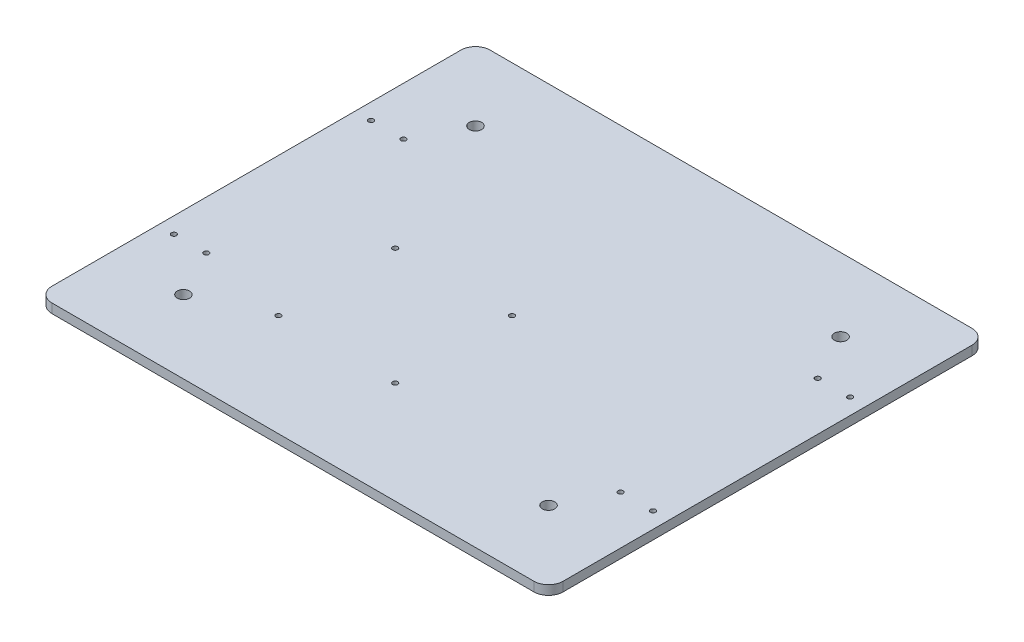
from build123d import *

# Parameters (mm, degrees)
SKETCH1_W                 = 350
SKETCH1_H                 = 300
BOSS_EXTRUDE1_DEPTH       = 6.35
SKETCH2_R                 = 4.25
CUT_EXTRUDE1_DEPTH        = 7.35
LPATTERN2_COUNT           = 2
LPATTERN2_PITCH           = 200
LPATTERN3_COUNT           = 2
LPATTERN3_PITCH           = 250
LPATTERN3_COPY_1_SKETCH_R = 4.25
LPATTERN3_COPY_1_DEPTH    = 7.35
FILLET1_R                 = 10
SKETCH4_R                 = 1.75
CUT_EXTRUDE2_DEPTH        = 7.35
LPATTERN5_COUNT           = 2
LPATTERN5_PITCH           = 80
LPATTERN5_COUNT_DIR2      = 2
LPATTERN5_PITCH_DIR2      = 80
SKETCH5_R                 = 1.75
CUT_EXTRUDE3_DEPTH        = 7.35
LPATTERN6_COUNT           = 2
LPATTERN6_PITCH           = 22.23
LPATTERN6_COUNT_DIR2      = 2
LPATTERN6_PITCH_DIR2      = 135
SKETCH7_R                 = 1.75
CUT_EXTRUDE4_DEPTH        = 7.35
LPATTERN9_COUNT           = 2
LPATTERN9_PITCH           = 22.23
LPATTERN9_COUNT_DIR2      = 2
LPATTERN9_PITCH_DIR2      = 135


with BuildPart() as part:
    # Sketch1 → Boss-Extrude1 (new body)
    with BuildSketch(Plane(origin=(0, 0, 0), x_dir=(1, 0, 0), z_dir=(0, 1, 0))):
        Rectangle(SKETCH1_W, SKETCH1_H)
    extrude(amount=BOSS_EXTRUDE1_DEPTH)

    # Sketch2 → Cut-Extrude1 (cut, through all)
    with BuildSketch(Plane.XZ):
        with Locations((-125, -100)):
            Circle(SKETCH2_R)
    cut_extrude1 = extrude(amount=-CUT_EXTRUDE1_DEPTH, mode=Mode.SUBTRACT)

    # LPattern2: Cut-Extrude1 ×2
    with Locations(*[(0, 0, i * LPATTERN2_PITCH) for i in range(1, LPATTERN2_COUNT)]):
        add(cut_extrude1, mode=Mode.SUBTRACT)

    # LPattern3: Cut-Extrude1 ×2
    with Locations(*[(i * LPATTERN3_PITCH, 0, 0) for i in range(1, LPATTERN3_COUNT)]):
        add(cut_extrude1, mode=Mode.SUBTRACT)

    # LPattern3 copy 1 sketch → LPattern3 copy 1 (cut, through all)
    with BuildSketch(Plane(origin=(250, 0, 200), x_dir=(1, 0, 0), z_dir=(0, -1, 0))):
        with Locations((-125, -100)):
            Circle(LPATTERN3_COPY_1_SKETCH_R)
    extrude(amount=-LPATTERN3_COPY_1_DEPTH, mode=Mode.SUBTRACT)

    # Fillet1
    fillet1_edges = [part.edges().sort_by_distance(p)[0] for p in [
        (-175, 3.175, -150),
        (175, 3.175, -150),
        (175, 3.175, 150),
        (-175, 3.175, 150),
    ]]
    fillet(fillet1_edges, radius=FILLET1_R)

    # Sketch4 → Cut-Extrude2 (cut, through all)
    with BuildSketch(Plane.XZ):
        Circle(SKETCH4_R)
    cut_extrude2 = extrude(amount=-CUT_EXTRUDE2_DEPTH, mode=Mode.SUBTRACT)

    # LPattern5: Cut-Extrude2 2 × 2
    with Locations(*[(-i * LPATTERN5_PITCH, 0, j * LPATTERN5_PITCH_DIR2) for i in range(LPATTERN5_COUNT) for j in range(LPATTERN5_COUNT_DIR2) if (i, j) != (0, 0)]):
        add(cut_extrude2, mode=Mode.SUBTRACT)

    # Sketch5 → Cut-Extrude3 (cut, through all)
    with BuildSketch(Plane.XZ):
        with Locations((-141.82, -67.5)):
            Circle(SKETCH5_R)
    cut_extrude3 = extrude(amount=-CUT_EXTRUDE3_DEPTH, mode=Mode.SUBTRACT)

    # LPattern6: Cut-Extrude3 2 × 2
    with Locations(*[(-i * LPATTERN6_PITCH, 0, j * LPATTERN6_PITCH_DIR2) for i in range(LPATTERN6_COUNT) for j in range(LPATTERN6_COUNT_DIR2) if (i, j) != (0, 0)]):
        add(cut_extrude3, mode=Mode.SUBTRACT)

    # Sketch7 → Cut-Extrude4 (cut, through all)
    with BuildSketch(Plane.XZ):
        with Locations((141.82, -67.5)):
            Circle(SKETCH7_R)
    cut_extrude4 = extrude(amount=-CUT_EXTRUDE4_DEPTH, mode=Mode.SUBTRACT)

    # LPattern9: Cut-Extrude4 2 × 2
    with Locations(*[(i * LPATTERN9_PITCH, 0, j * LPATTERN9_PITCH_DIR2) for i in range(LPATTERN9_COUNT) for j in range(LPATTERN9_COUNT_DIR2) if (i, j) != (0, 0)]):
        add(cut_extrude4, mode=Mode.SUBTRACT)


solid = part.part
